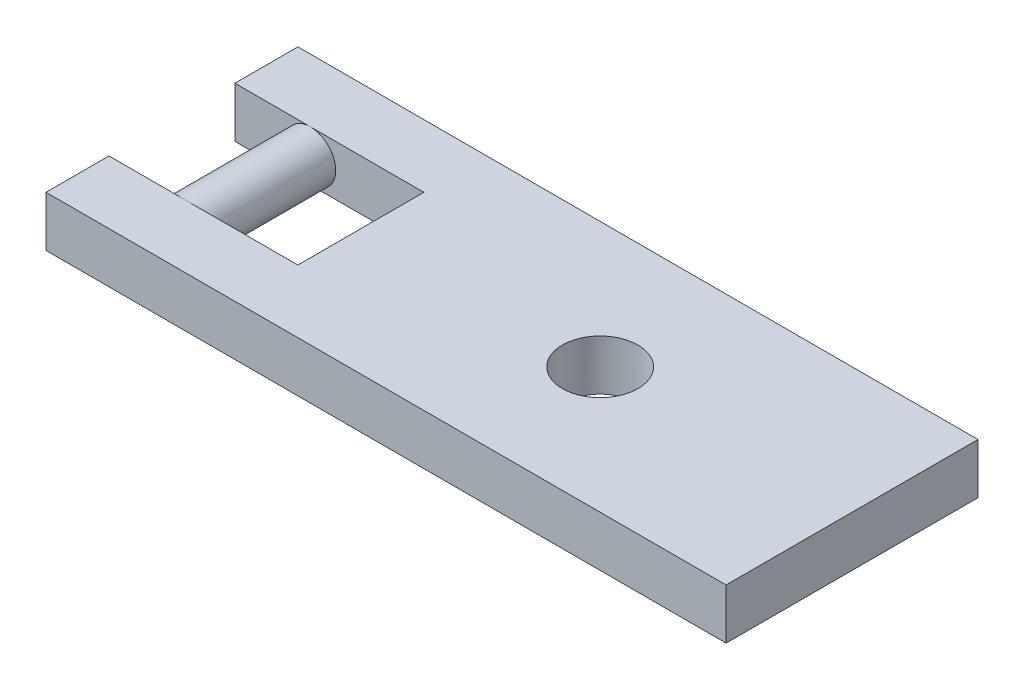
from build123d import *

# Parameters (mm, degrees)
Y_KSEKLIK_EKSTR_ZYON1_DEPTH = 5
IZIM2_W                     = 15
IZIM2_H                     = 5
KES_EKSTR_ZYON1_DEPTH       = 10
IZIM4_R                     = 1
Y_KSEKLIK_EKSTR_ZYON2_DEPTH = 2.5
IZIM5_R                     = 1.5
KES_EKSTR_ZYON2_DEPTH       = 5


with BuildPart() as part:
    # Çizim1 → Yükseklik-Ekstrüzyon1 (new body, symmetric)
    with BuildSketch(Plane.XY):
        Polygon((-29.798797212, 38.403805497), (-4.798797212, 38.403805497), (-4.798797212, 40.403805497), (-31.798797212, 40.403805497), (-31.798797212, 38.403805497), align=None)
    extrude(amount=Y_KSEKLIK_EKSTR_ZYON1_DEPTH, both=True)

    # Çizim2 → Kes-Ekstrüzyon1 (cut)
    with BuildSketch(Plane(origin=(0, 40.403805497, 0), x_dir=(1, 0, 0), z_dir=(0, 1, 0))):
        with Locations((-31.798797212, 0)):
            Rectangle(IZIM2_W, IZIM2_H)
    extrude(amount=-KES_EKSTR_ZYON1_DEPTH, mode=Mode.SUBTRACT)

    # Çizim4 → Yükseklik-Ekstrüzyon2 (add, symmetric)
    with BuildSketch(Plane.XY):
        with Locations((-28.798797212, 39.403805497)):
            Circle(IZIM4_R)
    extrude(amount=Y_KSEKLIK_EKSTR_ZYON2_DEPTH, both=True)

    # Çizim5 → Kes-Ekstrüzyon2 (cut)
    with BuildSketch(Plane(origin=(0, 40.403805497, 0), x_dir=(1, 0, 0), z_dir=(0, 1, 0))):
        with Locations((-14.798797212, 0)):
            Circle(IZIM5_R)
    extrude(amount=-KES_EKSTR_ZYON2_DEPTH, mode=Mode.SUBTRACT)


solid = part.part
